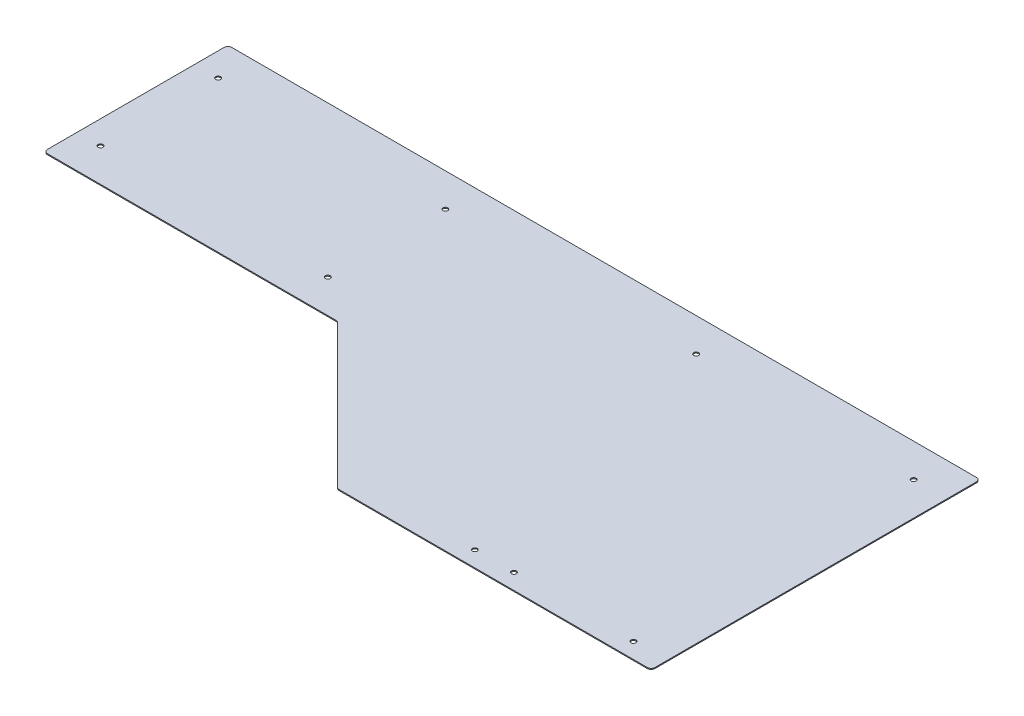
from build123d import *

# Parameters (mm, degrees)
BOSS_EXTRUDE1_DEPTH            = 1.5875
F_5_16_0_3125_DIAMETER_HOLE1_D = 7.9375
FILLET1_R                      = 6.35


with BuildPart() as part:
    # Sketch1 → Boss-Extrude1 (new body)
    with BuildSketch(Plane(origin=(0, 0, 0), x_dir=(1, 0, 0), z_dir=(0, 1, 0))):
        with BuildLine():
            Line((-1219.2, 234.95), (-745.580256121, 234.95))
            ThreePointArc((-745.580256121, 234.95), (-743.150216326, 234.466635031), (-741.090128061, 233.090128061))
            Line((-741.090128061, 233.090128061), (-509.859871939, 1.859871939))
            ThreePointArc((-509.859871939, 1.859871939), (-507.799783674, 0.483364969), (-505.369743879, 0))
            Line((-505.369743879, 0), (0, 0))
            Line((0, 0), (0, 533.4))
            Line((0, 533.4), (-1219.2, 533.4))
            Line((-1219.2, 533.4), (-1219.2, 234.95))
        make_face()
    extrude(amount=BOSS_EXTRUDE1_DEPTH)

    # 5/16 (0.3125) Diameter Hole1 (through all)
    with Locations(Plane(origin=(0, 1.5875, 0), x_dir=(1, 0, 0), z_dir=(0, 1, 0))):
        with Locations((-1181.1, 479.425), (-1181.1, 288.925), (-812.8, 288.925), (-812.8, 479.425), (-406.4, 479.425), (-53.975, 479.425), (-53.975, 25.4), (-247.65, 25.4), (-311.15, 25.4)):
            Hole(F_5_16_0_3125_DIAMETER_HOLE1_D / 2)

    # Fillet1
    fillet1_edges = [part.edges().sort_by_distance(p)[0] for p in [
        (-1219.2, 0.79375, -234.95),
        (-1219.2, 0.79375, -533.4),
        (0, 0.79375, -533.4),
        (0, 0.79375, 0),
    ]]
    fillet(fillet1_edges, radius=FILLET1_R)


solid = part.part
